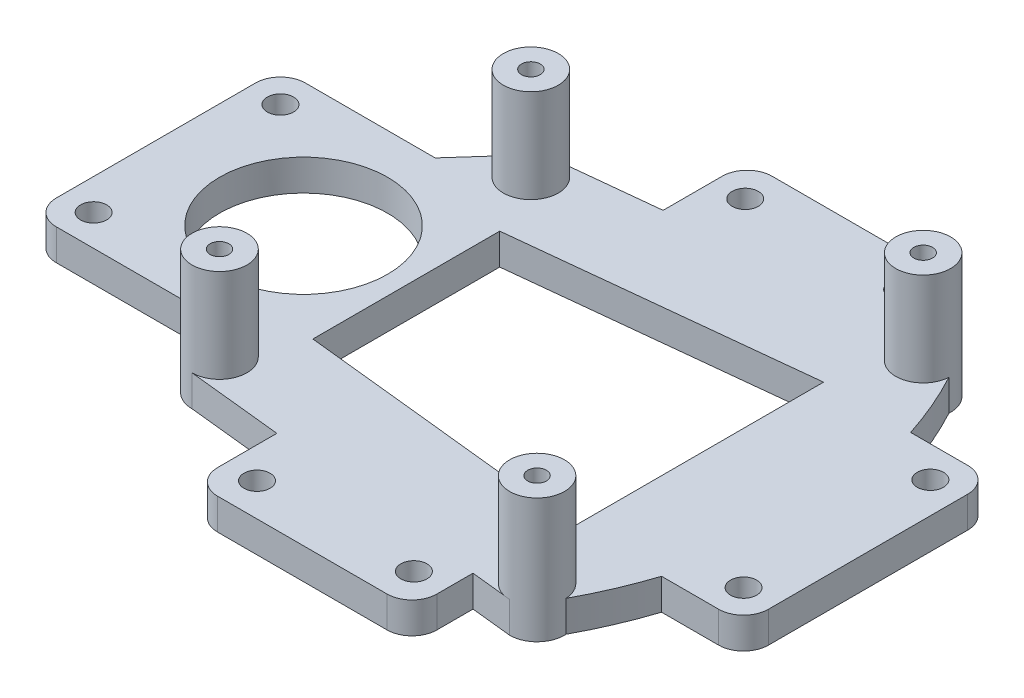
from build123d import *

# Parameters (mm, degrees)
SKETCH7_R             = 4.411628617
SKETCH7_R_2           = 1.499999999
BOSS_EXTRUDE1_DEPTH   = 15
SKETCH7_R_3           = 4.404719082
BOSS_EXTRUDE1_2_DEPTH = 15
BOSS_EXTRUDE1_3_DEPTH = 15
BOSS_EXTRUDE1_4_DEPTH = 15
SKETCH8_R             = 3.5
CUT_EXTRUDE1_DEPTH    = 5
SKETCH9_R             = 3.5
BOSS_EXTRUDE9_DEPTH   = 5
SKETCH12_R            = 2.1
BOSS_EXTRUDE10_DEPTH  = 5
FILLET3_R             = 4
SKETCH13_W            = 20
SKETCH13_H            = 20
SKETCH13_R            = 2.383284349
BOSS_EXTRUDE11_DEPTH  = 5
FILLET4_R             = 4
SKETCH14_R            = 2.383284349
SKETCH14_R_2          = 2.1
SKETCH14_W            = 20
SKETCH14_H            = 40
BOSS_EXTRUDE12_DEPTH  = 5
FILLET5_R             = 4
SKETCH15_W            = 31.82070186
SKETCH15_H            = 40
SKETCH15_R            = 2.1
BOSS_EXTRUDE13_DEPTH  = 5
FILLET6_R             = 4
SKETCH16_R            = 3.5
SKETCH16_R_2          = 1.499999999
BOSS_EXTRUDE14_DEPTH  = 15
CUT_EXTRUDE3_DEPTH    = 15
SKETCH18_R            = 13.5
CUT_EXTRUDE6_DEPTH    = 21


with BuildPart() as part:
    # Sketch7 → Boss-Extrude1 (new body)
    with BuildSketch(Plane(origin=(0, 0, 0), x_dir=(1, 0, 0), z_dir=(0, 1, 0))):
        with Locations((-35.224970632, 25)):
            Circle(SKETCH7_R)
        with Locations((-35.224970632, 25)):
            Circle(SKETCH7_R_2, mode=Mode.SUBTRACT)
    extrude(amount=-BOSS_EXTRUDE1_DEPTH)


with BuildPart() as body_2:
    # Sketch7 → Boss-Extrude1 2 (new body)
    with BuildSketch(Plane(origin=(0, 0, 0), x_dir=(1, 0, 0), z_dir=(0, 1, 0))):
        with Locations((21.775029368, 31)):
            Circle(SKETCH7_R_3)
        with Locations((21.775029368, 31)):
            Circle(SKETCH7_R_2, mode=Mode.SUBTRACT)
    extrude(amount=-BOSS_EXTRUDE1_2_DEPTH)


with BuildPart() as body_3:
    # Sketch7 → Boss-Extrude1 3 (new body)
    with BuildSketch(Plane(origin=(0, 0, 0), x_dir=(1, 0, 0), z_dir=(0, 1, 0))):
        with Locations((21.775029368, -31)):
            Circle(SKETCH7_R_3)
        with Locations((21.775029368, -31)):
            Circle(SKETCH7_R_2, mode=Mode.SUBTRACT)
    extrude(amount=-BOSS_EXTRUDE1_3_DEPTH)


with BuildPart() as body_4:
    # Sketch7 → Boss-Extrude1 4 (new body)
    with BuildSketch(Plane(origin=(0, 0, 0), x_dir=(1, 0, 0), z_dir=(0, 1, 0))):
        with Locations((-35.224970632, -25)):
            Circle(SKETCH7_R)
        with Locations((-35.224970632, -25)):
            Circle(SKETCH7_R_2, mode=Mode.SUBTRACT)
    extrude(amount=-BOSS_EXTRUDE1_4_DEPTH)


with BuildPart() as cut_extrude1_tool:
    # Sketch8 → Cut-Extrude1 (new body)
    with BuildSketch(Plane(origin=(0, -15, 0), x_dir=(-1, 0, 0), z_dir=(0, -1, 0))):
        with Locations((35.224970632, -25)):
            Circle(SKETCH8_R)
        with Locations((-21.775029368, -31)):
            Circle(SKETCH8_R)
        with Locations((35.224970632, 25)):
            Circle(SKETCH8_R)
        with Locations((-21.775029368, 31)):
            Circle(SKETCH8_R)
    extrude(amount=-CUT_EXTRUDE1_DEPTH)


with BuildPart() as part_1:
    add(part.part)

    # Cut-Extrude1: cut by cut_extrude1_tool
    add(cut_extrude1_tool.part, mode=Mode.SUBTRACT)



with BuildPart() as body_2_1:
    add(body_2.part)

    # Cut-Extrude1: cut by cut_extrude1_tool
    add(cut_extrude1_tool.part, mode=Mode.SUBTRACT)


with BuildPart() as body_3_1:
    add(body_3.part)

    # Cut-Extrude1: cut by cut_extrude1_tool
    add(cut_extrude1_tool.part, mode=Mode.SUBTRACT)


with BuildPart() as body_4_1:
    add(body_4.part)

    # Cut-Extrude1: cut by cut_extrude1_tool
    add(cut_extrude1_tool.part, mode=Mode.SUBTRACT)


with BuildPart() as part_2:
    add(part_1.part)

    add(body_2_1.part)  # Boss-Extrude9 merges body 2

    add(body_3_1.part)  # Boss-Extrude9 merges body 3

    add(body_4_1.part)  # Boss-Extrude9 merges body 4
    # Sketch9 → Boss-Extrude9 (add)
    with BuildSketch(Plane(origin=(0, -15, 0), x_dir=(-1, 0, 0), z_dir=(0, -1, 0))):
        with BuildLine():
            Line((38.764660529, -27.633070923), (55.562895144, -8.838834765))
            ThreePointArc((55.562895144, -8.838834765), (59.224060379, 0), (55.562895144, 8.838834765))
            Line((55.562895144, 8.838834765), (38.764660529, 27.633070923))
            ThreePointArc((38.764660529, 27.633070923), (37.205669501, 28.941991761), (35.224970632, 29.411628617))
            Line((35.224970632, 29.411628617), (-20.858915448, 35.308397089))
            Line((-20.858915448, 35.308397089), (-21.775029368, 35.404719082))
            ThreePointArc((-21.775029368, 35.404719082), (-24.985189946, 34.016027065), (-26.171192213, 30.725587114))
            ThreePointArc((-26.171192213, 30.725587114), (-33.931933496, 0), (-26.171192213, -30.725587114))
            ThreePointArc((-26.171192213, -30.725587114), (-24.985189946, -34.016027065), (-21.775029368, -35.404719082))
            Line((-21.775029368, -35.404719082), (-20.858915448, -35.308397089))
            Line((-20.858915448, -35.308397089), (35.224970632, -29.411628617))
            ThreePointArc((35.224970632, -29.411628617), (37.205669501, -28.941991761), (38.764660529, -27.633070923))
        make_face()
        with Locations((-21.775029368, -31)):
            Circle(SKETCH9_R, mode=Mode.SUBTRACT)
        with Locations((35.224970632, -25)):
            Circle(SKETCH9_R, mode=Mode.SUBTRACT)
        with Locations((-21.775029368, 31)):
            Circle(SKETCH9_R, mode=Mode.SUBTRACT)
        with Locations((35.224970632, 25)):
            Circle(SKETCH9_R, mode=Mode.SUBTRACT)
    extrude(amount=BOSS_EXTRUDE9_DEPTH)

    # Sketch12 → Boss-Extrude10 (add)
    with BuildSketch(Plane(origin=(0, -15, 0), x_dir=(1, 0, 0), z_dir=(0, 1, 0))):
        Polygon((0, 29.508444845), (15.196340386, 29.508444845), (15.196340386, 44.508444845), (-20, 44.508444845), (-20, 29.508444845), (-15, 29.508444845), align=None)
        with Locations((-15, 39.200262185)):
            Circle(SKETCH12_R, mode=Mode.SUBTRACT)
        with Locations((10.196340386, 39.200262185)):
            Circle(SKETCH12_R, mode=Mode.SUBTRACT)
        Polygon((-20, -44.508444845), (-20, -29.508444845), (-15, -29.508444845), (0, -29.508444845), (15.196340386, -29.508444845), (15.196340386, -44.508444845), align=None)
        with Locations((-15, -39.200262185)):
            Circle(SKETCH12_R, mode=Mode.SUBTRACT)
        with Locations((10.196340386, -39.200262185)):
            Circle(SKETCH12_R, mode=Mode.SUBTRACT)
    extrude(amount=-BOSS_EXTRUDE10_DEPTH)

    # Fillet3
    fillet3_edges = [part_2.edges().sort_by_distance(p)[0] for p in [
        (15.196340386, -17.5, 44.508444845),
        (-20, -17.5, 44.508444845),
        (15.196340386, -17.5, -44.508444845),
        (-20, -17.5, -44.508444845),
    ]]
    fillet(fillet3_edges, radius=FILLET3_R)

    # Sketch13 → Boss-Extrude11 (add)
    with BuildSketch(Plane(origin=(0, -15, 0), x_dir=(1, 0, 0), z_dir=(0, 1, 0))):
        with Locations((-60.435748909, 0)):
            Rectangle(SKETCH13_W, SKETCH13_H)
        with Locations((-65.435748909, 5)):
            Circle(SKETCH13_R, mode=Mode.SUBTRACT)
        with Locations((-65.435748909, -5)):
            Circle(SKETCH13_R, mode=Mode.SUBTRACT)
    extrude(amount=-BOSS_EXTRUDE11_DEPTH)

    # Fillet4
    fillet4_edges = [part_2.edges().sort_by_distance(p)[0] for p in [
        (-70.435748909, -17.5, -10),
        (-70.435748909, -17.5, 10),
    ]]
    fillet(fillet4_edges, radius=FILLET4_R)

    # Sketch14 → Boss-Extrude12 (add)
    with BuildSketch(Plane(origin=(0, -15, 0), x_dir=(1, 0, 0), z_dir=(0, 1, 0))):
        with Locations((-65.435748909, 5)):
            Circle(SKETCH14_R)
        with Locations((-65.435748909, 5)):
            Circle(SKETCH14_R_2, mode=Mode.SUBTRACT)
        with Locations((-65.435748909, -5)):
            Circle(SKETCH14_R)
        with Locations((-65.435748909, -5)):
            Circle(SKETCH14_R_2, mode=Mode.SUBTRACT)
        with Locations((33.931933496, 0)):
            Rectangle(SKETCH14_W, SKETCH14_H)
        with Locations((38.931933496, 15)):
            Circle(SKETCH14_R_2, mode=Mode.SUBTRACT)
        with Locations((38.931933496, -15)):
            Circle(SKETCH14_R_2, mode=Mode.SUBTRACT)
    extrude(amount=-BOSS_EXTRUDE12_DEPTH)

    # Fillet5
    fillet5_edges = [part_2.edges().sort_by_distance(p)[0] for p in [
        (43.931933496, -17.5, -20),
        (43.931933496, -17.5, 20),
    ]]
    fillet(fillet5_edges, radius=FILLET5_R)

    # Sketch15 → Boss-Extrude13 (add)
    with BuildSketch(Plane(origin=(0, -15, 0), x_dir=(1, 0, 0), z_dir=(0, 1, 0))):
        with Locations((-54.525048972, 0)):
            Rectangle(SKETCH15_W, SKETCH15_H)
        with Locations((-65.435748909, 15)):
            Circle(SKETCH15_R, mode=Mode.SUBTRACT)
        with Locations((-65.435748909, -15)):
            Circle(SKETCH15_R, mode=Mode.SUBTRACT)
    extrude(amount=-BOSS_EXTRUDE13_DEPTH)

    # Fillet6
    fillet6_edges = [part_2.edges().sort_by_distance(p)[0] for p in [
        (-70.435399902, -17.5, -20),
        (-70.435399902, -17.5, 20),
    ]]
    fillet(fillet6_edges, radius=FILLET6_R)

    # Sketch16 → Boss-Extrude14 (add)
    with BuildSketch(Plane(origin=(0, -20, 0), x_dir=(-1, 0, 0), z_dir=(0, -1, 0))):
        with Locations((-21.775029368, -31)):
            Circle(SKETCH16_R)
        with Locations((-21.775029368, -31)):
            Circle(SKETCH16_R_2, mode=Mode.SUBTRACT)
        with Locations((-21.775029368, 31)):
            Circle(SKETCH16_R)
        with Locations((-21.775029368, 31)):
            Circle(SKETCH16_R_2, mode=Mode.SUBTRACT)
        with Locations((35.224970632, 25)):
            Circle(SKETCH16_R)
        with Locations((35.224970632, 25)):
            Circle(SKETCH16_R_2, mode=Mode.SUBTRACT)
        with Locations((35.224970632, -25)):
            Circle(SKETCH16_R)
        with Locations((35.224970632, -25)):
            Circle(SKETCH16_R_2, mode=Mode.SUBTRACT)
    extrude(amount=-BOSS_EXTRUDE14_DEPTH)

    # Sketch17 → Cut-Extrude3 (cut)
    with BuildSketch(Plane(origin=(0, -15, 0), x_dir=(1, 0, 0), z_dir=(0, 1, 0))):
        Polygon((-30.224970632, 15), (16.775029368, 20), (16.775029368, -20), (-30.224970632, -15), align=None)
    extrude(amount=-CUT_EXTRUDE3_DEPTH, mode=Mode.SUBTRACT)

    # Sketch18 → Cut-Extrude6 (cut, through all)
    with BuildSketch(Plane(origin=(0, 0, 0), x_dir=(1, 0, 0), z_dir=(0, 1, 0))):
        with Locations((-46.724970632, 0)):
            Circle(SKETCH18_R)
    extrude(amount=-CUT_EXTRUDE6_DEPTH, mode=Mode.SUBTRACT)


solid = part_2.part
